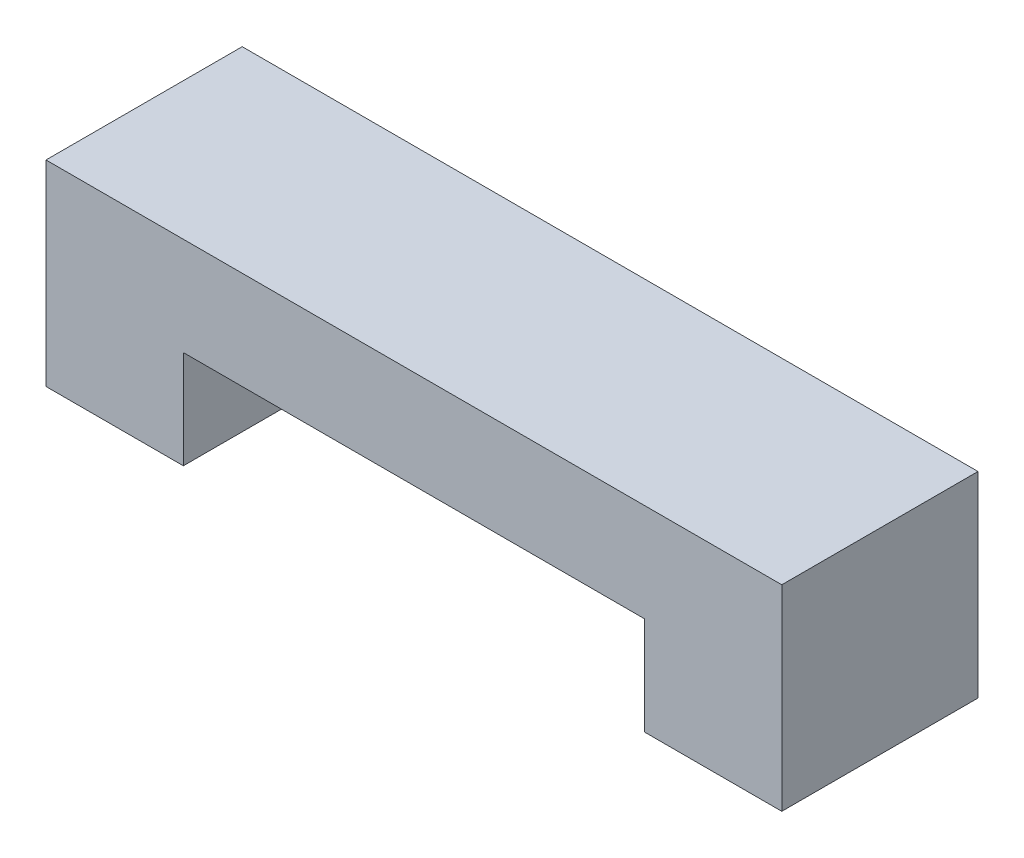
from build123d import *

# Parameters (mm, degrees)
CROQUIS1_W              = 37.5
CROQUIS1_H              = 10
SALIENTE_EXTRUIR1_DEPTH = 5
CROQUIS1_3_W            = 7
CROQUIS1_3_H            = 10
CROQUIS1_3_R            = 1.5
SALIENTE_EXTRUIR2_DEPTH = 5


with BuildPart() as part:
    # Croquis1 → Saliente-Extruir1 (new body)
    with BuildSketch(Plane(origin=(0, 0, 0), x_dir=(1, 0, 0), z_dir=(0, 1, 0))):
        Rectangle(CROQUIS1_W, CROQUIS1_H)
    extrude(amount=SALIENTE_EXTRUIR1_DEPTH)

    # Croquis1_3 → Saliente-Extruir2 (add)
    # profile 1 of 2: a face of its own
    with BuildSketch(Plane(origin=(0, 0, 0), x_dir=(1, 0, 0), z_dir=(0, 1, 0))):
        with Locations((-15.25, 0)):
            Rectangle(CROQUIS1_3_W, CROQUIS1_3_H)
        with Locations((-15, 0)):
            Circle(CROQUIS1_3_R, mode=Mode.SUBTRACT)
    # profile 2 of 2: a face of its own
    with BuildSketch(Plane(origin=(0, 0, 0), x_dir=(1, 0, 0), z_dir=(0, 1, 0))):
        with Locations((15.25, 0)):
            Rectangle(CROQUIS1_3_W, CROQUIS1_3_H)
        with Locations((15, 0)):
            Circle(CROQUIS1_3_R, mode=Mode.SUBTRACT)
    extrude(amount=-SALIENTE_EXTRUIR2_DEPTH)


solid = part.part
